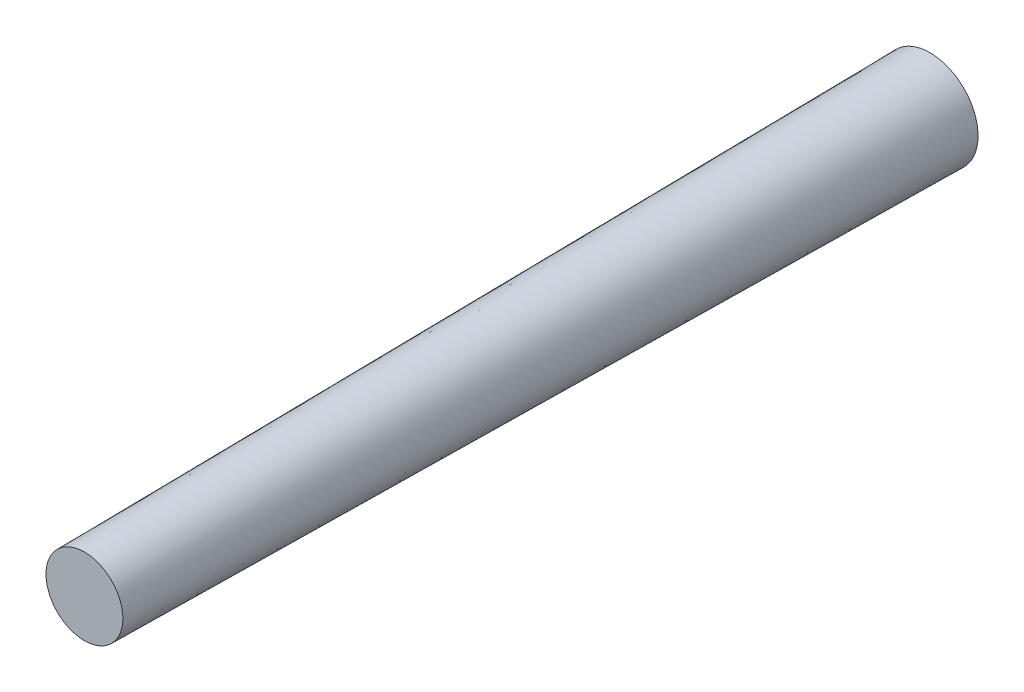
from build123d import *


with BuildPart() as part:
    # Sketch1 → Revolve1 (revolve)
    with BuildSketch(Plane(origin=(0, 0, 0), x_dir=(1, 0, 0), z_dir=(0, 1, 0))):
        Polygon((0, 22), (0, -22), (2, -22), (2.5, 22), align=None)
    revolve(axis=Axis((0, 0, -92.737159153), (0, 0, 1)))


solid = part.part
